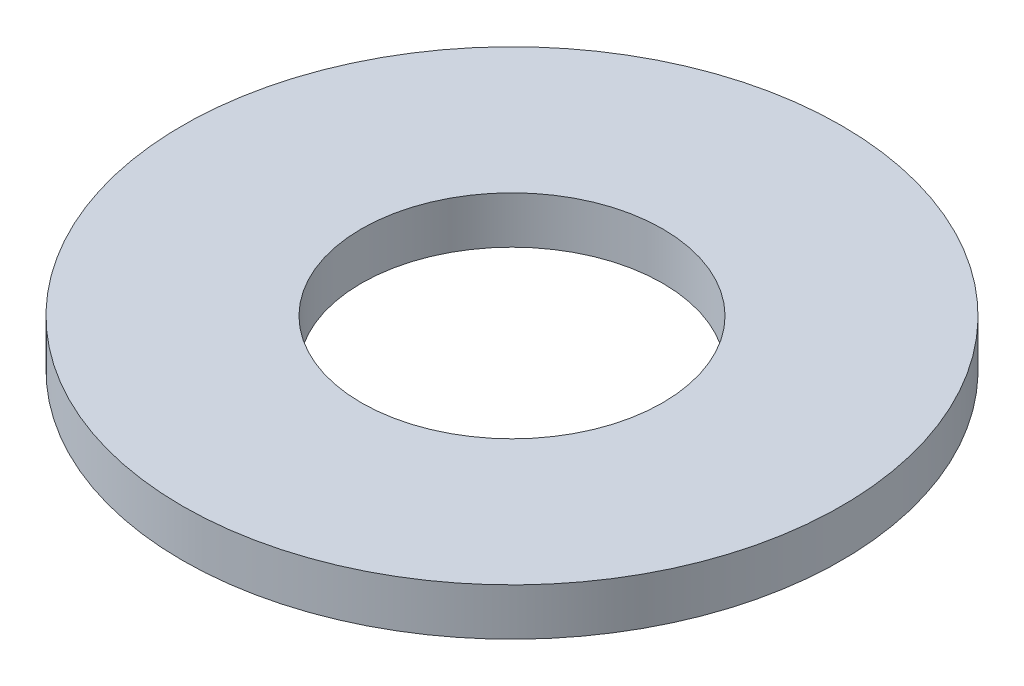
from build123d import *

# Parameters (mm, degrees)
CROQUIS1_R              = 3.5
CROQUIS1_R_2            = 1.6
SALIENTE_EXTRUIR1_DEPTH = 0.5


with BuildPart() as part:
    # Croquis1 → Saliente-Extruir1 (new body)
    with BuildSketch(Plane(origin=(0, 0, 0), x_dir=(1, 0, 0), z_dir=(0, 1, 0))):
        Circle(CROQUIS1_R)
        Circle(CROQUIS1_R_2, mode=Mode.SUBTRACT)
    extrude(amount=SALIENTE_EXTRUIR1_DEPTH)


solid = part.part
